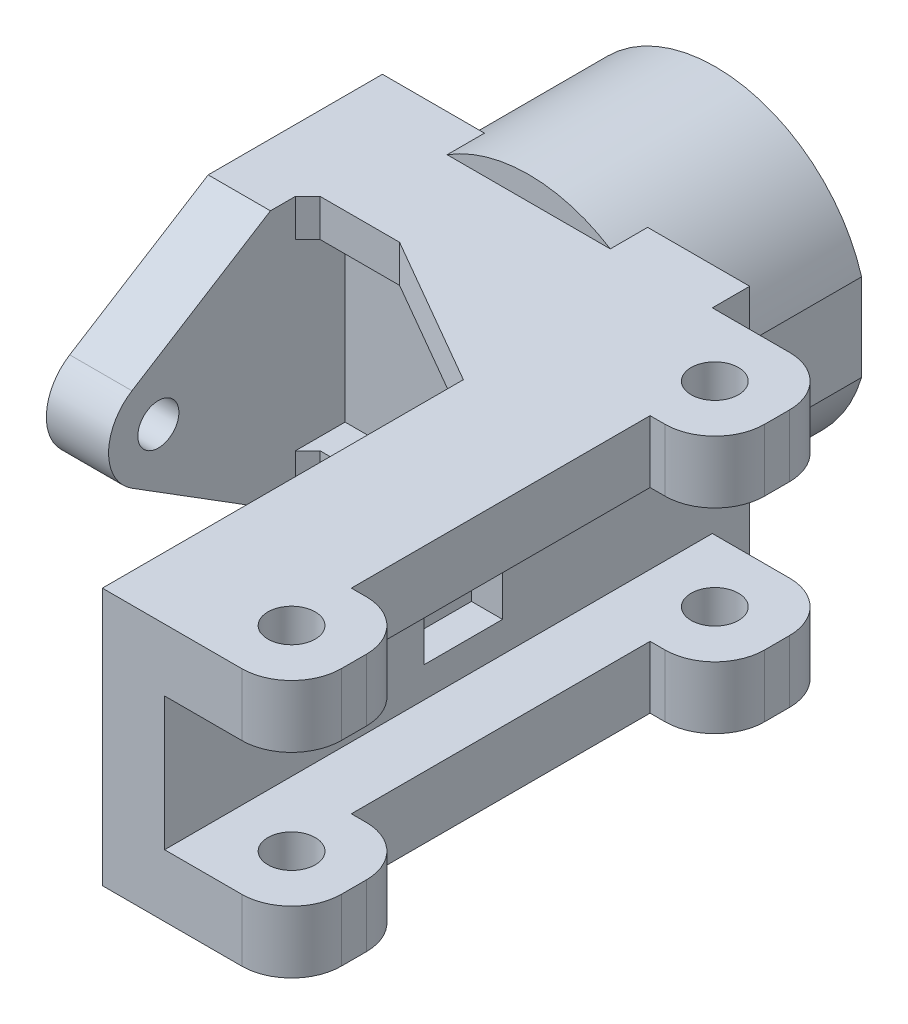
from build123d import *

# Parameters (mm, degrees)
SKETCH_1_R               = 6.325
EXTRUDE_1_DEPTH          = 15
SKETCH_2_W               = 29.5
SKETCH_2_H               = 20.7
EXTRUDE_2_DEPTH          = 5
SKETCH_3_W               = 39
SKETCH_3_H               = 20.7
SKETCH_3_R               = 1.65
EXTRUDE_3_DEPTH          = 5
SKETCH_4_W               = 10
SKETCH_4_H               = 5
EXTRUDE_4_DEPTH          = 10.2
SKETCH_5_R               = 1.9
CUT_EXTRUDE_1_DEPTH      = 21.7
FILLET_1_R               = 4
SKETCH_8_W               = 24
SKETCH_8_H               = 5
EXTRUDE_6_DEPTH          = 5
SKETCH_9_R               = 1.65
EXTRUDE_7_DEPTH          = 5
EXTRUDE_5_DEPTH          = 3
CHAMFER_2_SIZE           = 1
SKETCH_10_W              = 6.3
SKETCH_10_H              = 5.8
CUT_EXTRUDE_2_DEPTH      = 2.5
SKETCH_11_R              = 1.65
CUT_EXTRUDE_3_DEPTH      = 25.95
CUT_EXTRUDE_3_DEPTH_BACK = 15.75
CHAMFER_3_SIZE           = 1
CUT_EXTRUDE_4_DEPTH      = 1
CUT_EXTRUDE_4_DEPTH_BACK = 21.7
SKETCH_13_R              = 12.25
SKETCH_13_R_2            = 9.25
EXTRUDE_8_DEPTH          = 15
SKETCH_14_R              = 1.65
CUT_EXTRUDE_5_DEPTH      = 25.95
CUT_EXTRUDE_5_DEPTH_BACK = 15.75
SKETCH_15_W              = 4.137033229
SKETCH_15_H              = 7
CUT_EXTRUDE_6_DEPTH      = 15
EXTRUDE_9_DEPTH          = 3


with BuildPart() as part:
    # ｽｹｯﾁ1 → ﾎﾞｽ - 押し出し1 (new body)
    with BuildSketch(Plane.XY):
        Circle(SKETCH_1_R)
    extrude(amount=-EXTRUDE_1_DEPTH)

    # ｽｹｯﾁ2 → ﾎﾞｽ - 押し出し2 (add)
    with BuildSketch(Plane.XY):
        Rectangle(SKETCH_2_W, SKETCH_2_H)
    extrude(amount=EXTRUDE_2_DEPTH)

    # ｽｹｯﾁ3 → ﾎﾞｽ - 押し出し3 (add)
    with BuildSketch(Plane(origin=(14.75, 0, 0), x_dir=(0, 0, -1), z_dir=(1, 0, 0))):
        with Locations((-24.5, 0)):
            Rectangle(SKETCH_3_W, SKETCH_3_H)
        with Locations((-20, 0)):
            Circle(SKETCH_3_R, mode=Mode.SUBTRACT)
    extrude(amount=-EXTRUDE_3_DEPTH)

    # ｽｹｯﾁ4 → ﾎﾞｽ - 押し出し4 (add)
    with BuildSketch(Plane(origin=(14.75, 0, 0), x_dir=(0, 0, -1), z_dir=(1, 0, 0))):
        with Locations((-5, 7.85)):
            Rectangle(SKETCH_4_W, SKETCH_4_H)
        with Locations((-5, -7.85)):
            Rectangle(SKETCH_4_W, SKETCH_4_H)
        with Locations((-39, 7.85)):
            Rectangle(SKETCH_4_W, SKETCH_4_H)
        with Locations((-39, -7.85)):
            Rectangle(SKETCH_4_W, SKETCH_4_H)
    extrude(amount=EXTRUDE_4_DEPTH)

    # ｽｹｯﾁ5 → ｶｯﾄ - 押し出し1 (cut, through all)
    with BuildSketch(Plane.XZ.offset(10.35)):
        with Locations((19.95, 5)):
            Circle(SKETCH_5_R)
        with Locations((19.95, 39)):
            Circle(SKETCH_5_R)
    extrude(amount=-CUT_EXTRUDE_1_DEPTH, mode=Mode.SUBTRACT)

    # ﾌｨﾚｯﾄ1
    fillet_1_edges = [part.edges().sort_by_distance(p)[0] for p in [
        (24.95, 7.85, 0),
        (24.95, 7.85, 10),
        (24.95, -7.85, 0),
        (24.95, -7.85, 10),
        (24.95, -7.85, 44),
        (24.95, -7.85, 34),
        (24.95, 7.85, 44),
        (24.95, 7.85, 34),
    ]]
    fillet(fillet_1_edges, radius=FILLET_1_R)

    # ｽｹｯﾁ8 → ﾎﾞｽ - 押し出し6 (add)
    with BuildSketch(Plane(origin=(14.75, 0, 0), x_dir=(0, 0, -1), z_dir=(1, 0, 0))):
        with Locations((-22, 7.85)):
            Rectangle(SKETCH_8_W, SKETCH_8_H)
        with Locations((-22, -7.85)):
            Rectangle(SKETCH_8_W, SKETCH_8_H)
    extrude(amount=EXTRUDE_6_DEPTH)

    # ｽｹｯﾁ9 → ﾎﾞｽ - 押し出し7 (add)
    with BuildSketch(Plane.ZY.offset(14.75)):
        with BuildLine():
            Line((5, 10.35), (11, 10.35))
            Line((11, 10.35), (22.121751649, 3.390895153))
            ThreePointArc((22.121751649, 3.390895153), (24, 0), (22.121751649, -3.390895153))
            Line((22.121751649, -3.390895153), (11, -10.35))
            Line((11, -10.35), (5, -10.35))
            Line((5, -10.35), (5, 10.35))
        make_face()
        with Locations((20, 0)):
            Circle(SKETCH_9_R, mode=Mode.SUBTRACT)
    extrude(amount=-EXTRUDE_7_DEPTH)

    # ｽｹｯﾁ6 → ﾎﾞｽ - 押し出し5 (add)
    with BuildSketch(Plane.XZ.offset(10.35)):
        Polygon((-9.75, 5), (9.75, 5), (9.75, 15), (-2.374355653, 8), (-9.75, 8), align=None)
    extrude_5 = extrude(amount=-EXTRUDE_5_DEPTH)

    # ﾐﾗｰ1: ﾎﾞｽ - 押し出し5 across plane
    add(extrude_5.mirror(Plane.ZX))

    # 面取り2
    chamfer_2_edges = [part.edges().sort_by_distance(p)[0] for p in [
        (-9.75, -8.85, 8),
        (-9.75, 8.85, 8),
    ]]
    chamfer(chamfer_2_edges, length=CHAMFER_2_SIZE)

    # ｽｹｯﾁ10 → ｶｯﾄ - 押し出し2 (cut)
    with BuildSketch(Plane(origin=(14.75, 0, 0), x_dir=(0, 0, -1), z_dir=(1, 0, 0))):
        with Locations((-20, 0)):
            Rectangle(SKETCH_10_W, SKETCH_10_H)
    extrude(amount=-CUT_EXTRUDE_2_DEPTH, mode=Mode.SUBTRACT)

    # ｽｹｯﾁ11 → ｶｯﾄ - 押し出し3 (cut, two sides)
    with BuildSketch(Plane(origin=(0, 0, 0), x_dir=(0, 0, -1), z_dir=(1, 0, 0))) as cut_extrude_3_sk:
        with Locations((7.5, 0)):
            Circle(SKETCH_11_R)
    extrude(amount=CUT_EXTRUDE_3_DEPTH, mode=Mode.SUBTRACT)
    extrude(cut_extrude_3_sk.sketch, amount=-CUT_EXTRUDE_3_DEPTH_BACK, mode=Mode.SUBTRACT)

    # 面取り3
    chamfer_3_edges = [part.edges().sort_by_distance(p)[0] for p in [
        (-6.325, 0, -15),
    ]]
    chamfer(chamfer_3_edges, length=CHAMFER_3_SIZE)

    # ｽｹｯﾁ12 → ｶｯﾄ - 押し出し4 (cut, two sides)
    with BuildSketch(Plane(origin=(0, 10.35, 0), x_dir=(1, 0, 0), z_dir=(0, 1, 0))) as cut_extrude_4_sk:
        Polygon((-157.887970151, 0), (-20.856584832, 0), (30.621949215, 0), (167.653334534, 0), (167.653334534, 274.062770638), (-157.887970151, 274.062770638), align=None)
    extrude(amount=CUT_EXTRUDE_4_DEPTH, mode=Mode.SUBTRACT)
    extrude(cut_extrude_4_sk.sketch, amount=-CUT_EXTRUDE_4_DEPTH_BACK, mode=Mode.SUBTRACT)

    # ｽｹｯﾁ13 → ﾎﾞｽ - 押し出し8 (add)
    with BuildSketch(Plane(origin=(0, 0, 0), x_dir=(-1, 0, 0), z_dir=(0, 0, -1))):
        Circle(SKETCH_13_R)
        Circle(SKETCH_13_R_2, mode=Mode.SUBTRACT)
    extrude(amount=EXTRUDE_8_DEPTH)

    # ｽｹｯﾁ14 → ｶｯﾄ - 押し出し5 (cut, two sides)
    with BuildSketch(Plane(origin=(0, 0, 0), x_dir=(0, 0, -1), z_dir=(1, 0, 0))) as cut_extrude_5_sk:
        with Locations((7.5, 0)):
            Circle(SKETCH_14_R)
    extrude(amount=CUT_EXTRUDE_5_DEPTH, mode=Mode.SUBTRACT)
    extrude(cut_extrude_5_sk.sketch, amount=-CUT_EXTRUDE_5_DEPTH_BACK, mode=Mode.SUBTRACT)

    # ｽｹｯﾁ15 → ｶｯﾄ - 押し出し6 (cut)
    with BuildSketch(Plane(origin=(0, 0, -15), x_dir=(-1, 0, 0), z_dir=(0, 0, -1))):
        with Locations((-13.807873497, 0)):
            Rectangle(SKETCH_15_W, SKETCH_15_H)
        with Locations((13.807873497, 0)):
            Rectangle(SKETCH_15_W, SKETCH_15_H)
    extrude(amount=-CUT_EXTRUDE_6_DEPTH, mode=Mode.SUBTRACT)

    # ｽｹｯﾁ16 → ﾎﾞｽ - 押し出し9 (add)
    with BuildSketch(Plane(origin=(0, 0, 0), x_dir=(-1, 0, 0), z_dir=(0, 0, -1))):
        with BuildLine():
            Line((-11.739356882, 3.5), (-11.739356882, -3.5))
            ThreePointArc((-11.739356882, -3.5), (-9.766367935, -7.394630306), (-6.55286197, -10.35))
            Line((-6.55286197, -10.35), (-14.75, -10.35))
            Line((-14.75, -10.35), (-14.75, 10.35))
            Line((-14.75, 10.35), (-6.55286197, 10.35))
            ThreePointArc((-6.55286197, 10.35), (-9.766367935, 7.394630306), (-11.739356882, 3.5))
        make_face()
        with BuildLine():
            Line((6.55286197, -10.35), (14.75, -10.35))
            Line((14.75, -10.35), (14.75, 10.35))
            Line((14.75, 10.35), (6.55286197, 10.35))
            ThreePointArc((6.55286197, 10.35), (9.766367935, 7.394630306), (11.739356882, 3.5))
            Line((11.739356882, 3.5), (11.739356882, -3.5))
            ThreePointArc((11.739356882, -3.5), (9.766367935, -7.394630306), (6.55286197, -10.35))
        make_face()
    extrude(amount=EXTRUDE_9_DEPTH)


solid = part.part
